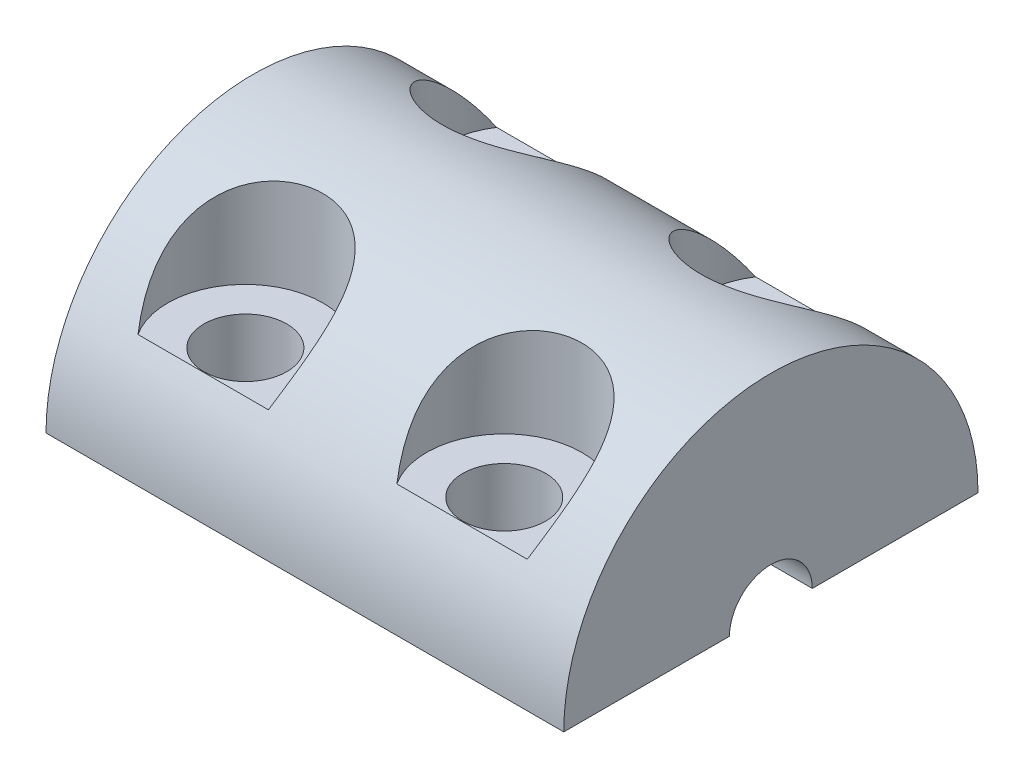
from build123d import *

# Parameters (mm, degrees)
BOSS_EXTRUDE1_DEPTH = 10
BOSS_EXTRUDE2_DEPTH = 10
SKETCH4_R           = 1.6
CUT_EXTRUDE1_DEPTH  = 10
SKETCH5_R           = 3
SKETCH5_R_2         = 1.6
CUT_EXTRUDE2_DEPTH  = 10


with BuildPart() as part:
    # Sketch2 → Boss-Extrude1 (new body)
    with BuildSketch(Plane(origin=(0, 0, 0), x_dir=(0, 0, -1), z_dir=(1, 0, 0))):
        with BuildLine():
            Line((-8, 0), (-1.6, 0))
            ThreePointArc((-1.6, 0), (0, 1.6), (1.6, 0))
            Line((1.6, 0), (8, 0))
            ThreePointArc((8, 0), (0, 8), (-8, 0))
        make_face()
    extrude(amount=BOSS_EXTRUDE1_DEPTH)

    # Sketch3 → Boss-Extrude2 (add)
    with BuildSketch(Plane.ZY):
        with BuildLine():
            Line((-8, 0), (-2.6, 0))
            ThreePointArc((-2.6, 0), (0, 2.6), (2.6, 0))
            Line((2.6, 0), (8, 0))
            ThreePointArc((8, 0), (0, 8), (-8, 0))
        make_face()
    extrude(amount=BOSS_EXTRUDE2_DEPTH)

    # Sketch4 → Cut-Extrude1 (cut)
    with BuildSketch(Plane.XZ):
        with Locations((-5, 5.3)):
            Circle(SKETCH4_R)
        with Locations((5, 5.3)):
            Circle(SKETCH4_R)
        with Locations((-5, -5.3)):
            Circle(SKETCH4_R)
        with Locations((5, -5.3)):
            Circle(SKETCH4_R)
    extrude(amount=-CUT_EXTRUDE1_DEPTH, mode=Mode.SUBTRACT)

    # Sketch5 → Cut-Extrude2 (cut)
    with BuildSketch(Plane(origin=(0, 4, 0), x_dir=(-1, 0, 0), z_dir=(0, -1, 0))):
        with Locations((-5, 5.3)):
            Circle(SKETCH5_R)
        with Locations((-5, 5.3)):
            Circle(SKETCH5_R_2, mode=Mode.SUBTRACT)
        with Locations((5, 5.3)):
            Circle(SKETCH5_R)
        with Locations((5, 5.3)):
            Circle(SKETCH5_R_2, mode=Mode.SUBTRACT)
        with Locations((5, -5.3)):
            Circle(SKETCH5_R)
        with Locations((-5, -5.3)):
            Circle(SKETCH5_R)
    extrude(amount=-CUT_EXTRUDE2_DEPTH, mode=Mode.SUBTRACT)


solid = part.part
